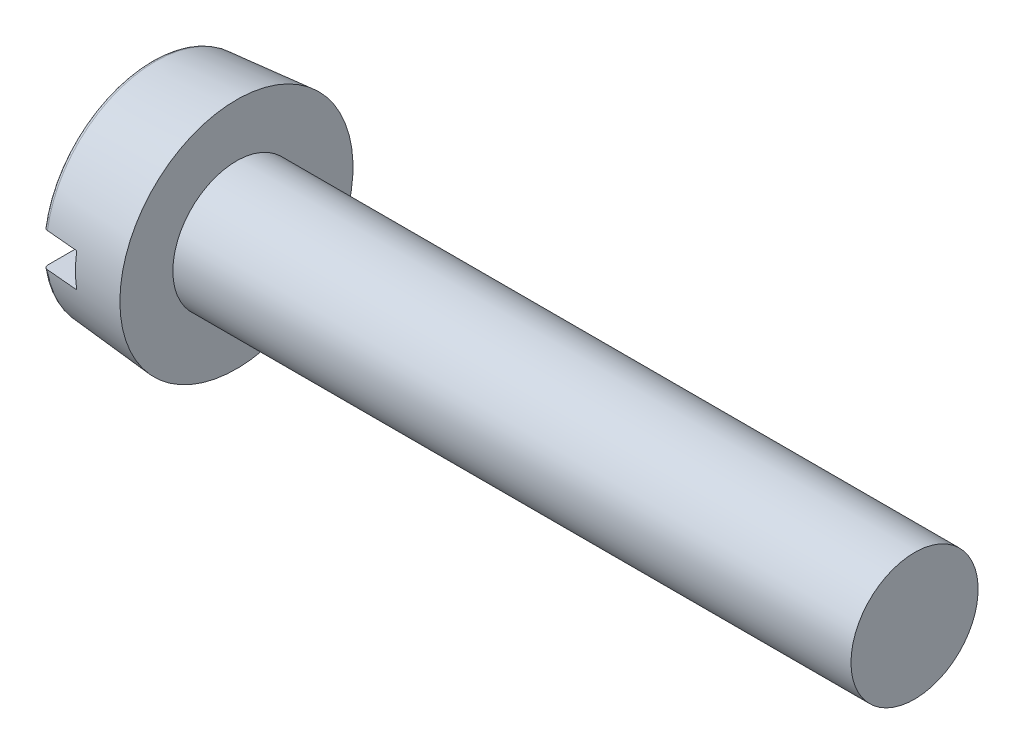
from build123d import *

# Parameters (mm, degrees)
FILLET2_R  = 0.1
SKETCH2_W  = 5.5
SKETCH2_H  = 0.8
SLOT_DEPTH = 0.85


with BuildPart() as part:
    # BodySke → Base-Revolve (revolve)
    with BuildSketch(Plane.XY):
        Polygon((2, 1.5), (2, 2.75), (0, 2.575022673), (0, 0), (18, 0), (18, 1.5), align=None)
    revolve(axis=Axis((-25.4, 0, 0), (1, 0, 0)))

    # Fillet2
    fillet2_edges = [part.edges().sort_by_distance(p)[0] for p in [
        (0, -2.575022673, 0),
    ]]
    fillet(fillet2_edges, radius=FILLET2_R)

    # Sketch2 → Slot (cut)
    with BuildSketch(Plane(origin=(0, 0, 0), x_dir=(0, 0, -1), z_dir=(1, 0, 0))):
        Rectangle(SKETCH2_W, SKETCH2_H)
    extrude(amount=SLOT_DEPTH, mode=Mode.SUBTRACT)


solid = part.part
